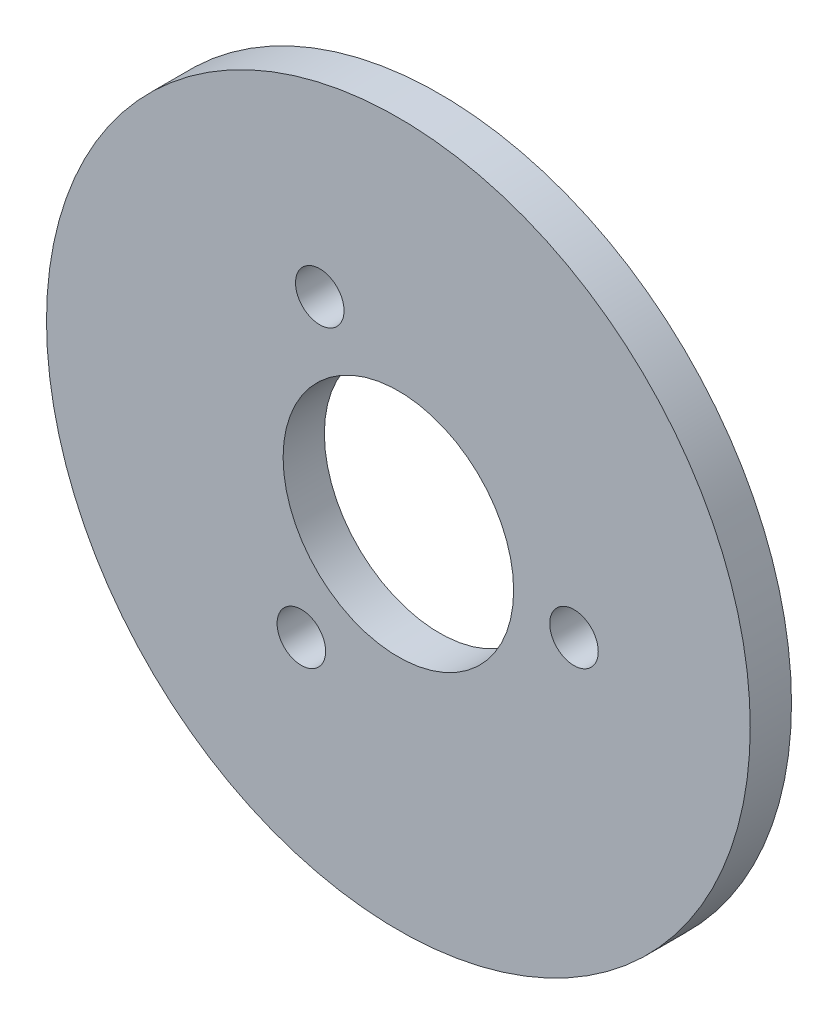
from build123d import *

# Parameters (mm, degrees)
SKETCH1_R           = 29
SKETCH1_R_2         = 9.5
SKETCH1_R_3         = 2
BOSS_EXTRUDE1_DEPTH = 3.4


with BuildPart() as part:
    # Sketch1 → Boss-Extrude1 (new body)
    with BuildSketch(Plane.XY):
        Circle(SKETCH1_R)
        Circle(SKETCH1_R_2, mode=Mode.SUBTRACT)
        with Locations((-6.478211144, 12.9723853)):
            Circle(SKETCH1_R_3, mode=Mode.SUBTRACT)
        with Locations((14.47352079, -0.875897228)):
            Circle(SKETCH1_R_3, mode=Mode.SUBTRACT)
        with Locations((-7.995309646, -12.096488072)):
            Circle(SKETCH1_R_3, mode=Mode.SUBTRACT)
    extrude(amount=BOSS_EXTRUDE1_DEPTH)


solid = part.part
